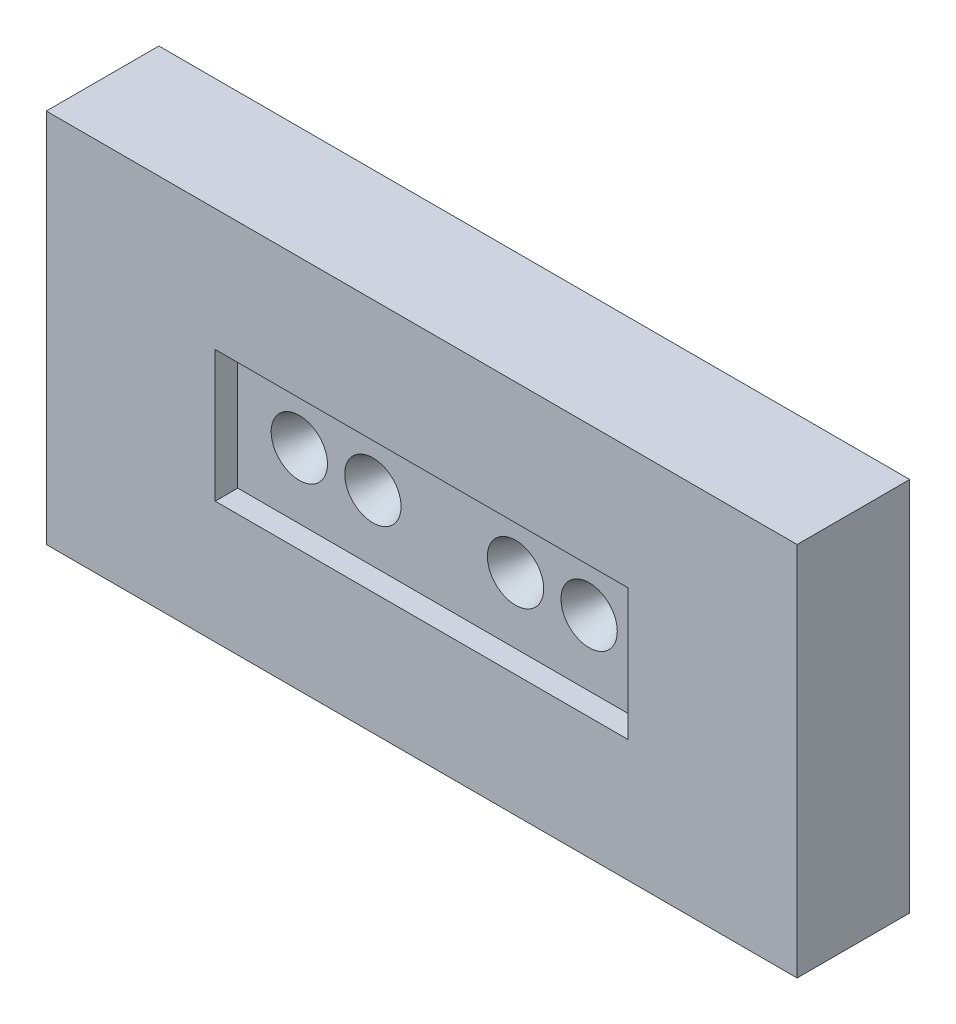
from build123d import *

# Parameters (mm, degrees)
SKETCH1_W           = 40
SKETCH1_H           = 20
BOSS_EXTRUDE1_DEPTH = 6
SKETCH2_W           = 22
SKETCH2_H           = 7
CUT_EXTRUDE1_DEPTH  = 1.2
SKETCH4_R           = 1.5
CUT_EXTRUDE2_DEPTH  = 2.8
CUT_EXTRUDE2_TAPER  = 23
SKETCH5_R           = 0.3
CUT_EXTRUDE3_DEPTH  = 2.5


with BuildPart() as part:
    # Sketch1 → Boss-Extrude1 (new body)
    with BuildSketch(Plane.XY):
        Rectangle(SKETCH1_W, SKETCH1_H)
    extrude(amount=BOSS_EXTRUDE1_DEPTH)

    # Sketch2 → Cut-Extrude1 (cut)
    with BuildSketch(Plane.XY.offset(6)):
        Rectangle(SKETCH2_W, SKETCH2_H)
    extrude(amount=-CUT_EXTRUDE1_DEPTH, mode=Mode.SUBTRACT)

    # Sketch4 → Cut-Extrude2 (cut)
    with BuildSketch(Plane.XY.offset(4.8)):
        with Locations((-7.72, 0)):
            Circle(SKETCH4_R)
        with Locations((-3.8, 0)):
            Circle(SKETCH4_R)
        with Locations((3.8, 0)):
            Circle(SKETCH4_R)
        with Locations((7.72, 0)):
            Circle(SKETCH4_R)
    extrude(amount=-CUT_EXTRUDE2_DEPTH, taper=CUT_EXTRUDE2_TAPER, mode=Mode.SUBTRACT)

    # Sketch5 → Cut-Extrude3 (cut)
    with BuildSketch(Plane.XY.offset(2)):
        with Locations((-7.72, 0)):
            Circle(SKETCH5_R)
        with Locations((-3.8, 0)):
            Circle(SKETCH5_R)
        with Locations((3.8, 0)):
            Circle(SKETCH5_R)
        with Locations((7.72, 0)):
            Circle(SKETCH5_R)
    extrude(amount=-CUT_EXTRUDE3_DEPTH, mode=Mode.SUBTRACT)


solid = part.part
